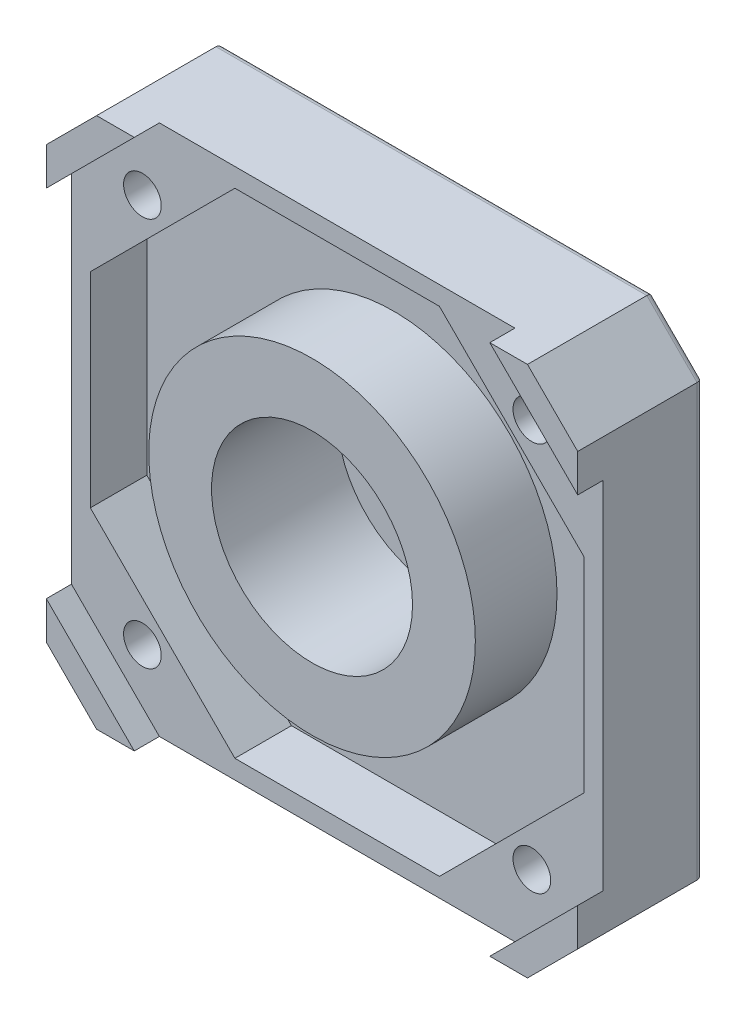
from build123d import *

# Parameters (mm, degrees)
BOSS_EXTRUDE1_DEPTH = 10
SKETCH17_R          = 11
BOSS_EXTRUDE4_DEPTH = 2
SKETCH18_R          = 13
CUT_EXTRUDE14_DEPTH = 6.5
SKETCH19_R          = 8
CUT_EXTRUDE15_DEPTH = 10
SKETCH20_R          = 4.5
CUT_EXTRUDE16_DEPTH = 3
SKETCH21_R          = 13
CUT_EXTRUDE17_DEPTH = 2
SKETCH23_R          = 1.5
CUT_EXTRUDE18_DEPTH = 13
SKETCH24_R          = 16
SKETCH24_R_2        = 11
CUT_EXTRUDE19_DEPTH = 0.25
FILLET9_R           = 0.5
CHAMFER1_SIZE       = 0.5


with BuildPart() as part:
    # Sketch2 → Boss-Extrude1 (new body)
    with BuildSketch(Plane.XY):
        Polygon((-21.15, 17.15), (-17.15, 21.15), (17.15, 21.15), (21.15, 17.15), (21.15, -17.15), (17.15, -21.15), (-17.15, -21.15), (-21.15, -17.15), align=None)
    extrude(amount=BOSS_EXTRUDE1_DEPTH)

    # Sketch17 → Boss-Extrude4 (add)
    with BuildSketch(Plane(origin=(0, 0, 0), x_dir=(-1, 0, 0), z_dir=(0, 0, -1))):
        Circle(SKETCH17_R)
    extrude(amount=BOSS_EXTRUDE4_DEPTH)

    # Sketch18 → Cut-Extrude14 (cut)
    with BuildSketch(Plane.XY.offset(10)):
        Polygon((8.139296501, 19.65), (-8.139296501, 19.65), (-19.65, 8.139296501), (-19.65, -8.139296501), (-8.139296501, -19.65), (8.139296501, -19.65), (19.65, -8.139296501), (19.65, 8.139296501), align=None)
        Circle(SKETCH18_R, mode=Mode.SUBTRACT)
    extrude(amount=-CUT_EXTRUDE14_DEPTH, mode=Mode.SUBTRACT)

    # Sketch19 → Cut-Extrude15 (cut)
    with BuildSketch(Plane.XY.offset(10)):
        Circle(SKETCH19_R)
    extrude(amount=-CUT_EXTRUDE15_DEPTH, mode=Mode.SUBTRACT)

    # Sketch20 → Cut-Extrude16 (cut, through all)
    with BuildSketch(Plane.XY):
        Circle(SKETCH20_R)
    extrude(amount=-CUT_EXTRUDE16_DEPTH, mode=Mode.SUBTRACT)

    # Sketch21 → Cut-Extrude17 (cut)
    with BuildSketch(Plane.XY.offset(10)):
        Polygon((-21.15, 14.15), (-14.15, 21.15), (14.15, 21.15), (21.15, 14.15), (21.15, -14.15), (14.15, -21.15), (-14.15, -21.15), (-21.15, -14.15), align=None)
        Circle(SKETCH21_R, mode=Mode.SUBTRACT)
    extrude(amount=-CUT_EXTRUDE17_DEPTH, mode=Mode.SUBTRACT)

    # Sketch23 → Cut-Extrude18 (cut, through all)
    with BuildSketch(Plane.XY.offset(10)):
        with Locations((-15.5, 15.5)):
            Circle(SKETCH23_R)
        with Locations((15.5, 15.5)):
            Circle(SKETCH23_R)
        with Locations((15.5, -15.5)):
            Circle(SKETCH23_R)
        with Locations((-15.5, -15.5)):
            Circle(SKETCH23_R)
    extrude(amount=-CUT_EXTRUDE18_DEPTH, mode=Mode.SUBTRACT)

    # Sketch24 → Cut-Extrude19 (cut)
    with BuildSketch(Plane(origin=(0, 0, 0), x_dir=(-1, 0, 0), z_dir=(0, 0, -1))):
        Circle(SKETCH24_R)
        Circle(SKETCH24_R_2, mode=Mode.SUBTRACT)
    extrude(amount=-CUT_EXTRUDE19_DEPTH, mode=Mode.SUBTRACT)

    # Fillet9
    fillet9_edges = [part.edges().sort_by_distance(p)[0] for p in [
        (-19.15, -19.15, 0),
        (-21.15, 0, 0),
        (11, 0, 0.25),
        (11, 0, -2),
        (-4.5, 0, -2),
        (-19.15, 19.15, 0),
        (0, 21.15, 0),
        (19.15, 19.15, 0),
        (21.15, 0, 0),
        (19.15, -19.15, 0),
        (0, -21.15, 0),
    ]]
    fillet(fillet9_edges, radius=FILLET9_R)

    # Chamfer1
    chamfer1_edges = [part.edges().sort_by_distance(p)[0] for p in [
        (-17, -15.5, 0),
        (14, -15.5, 0),
        (14, 15.5, 0),
        (-17, 15.5, 0),
    ]]
    chamfer(chamfer1_edges, length=CHAMFER1_SIZE)


solid = part.part
